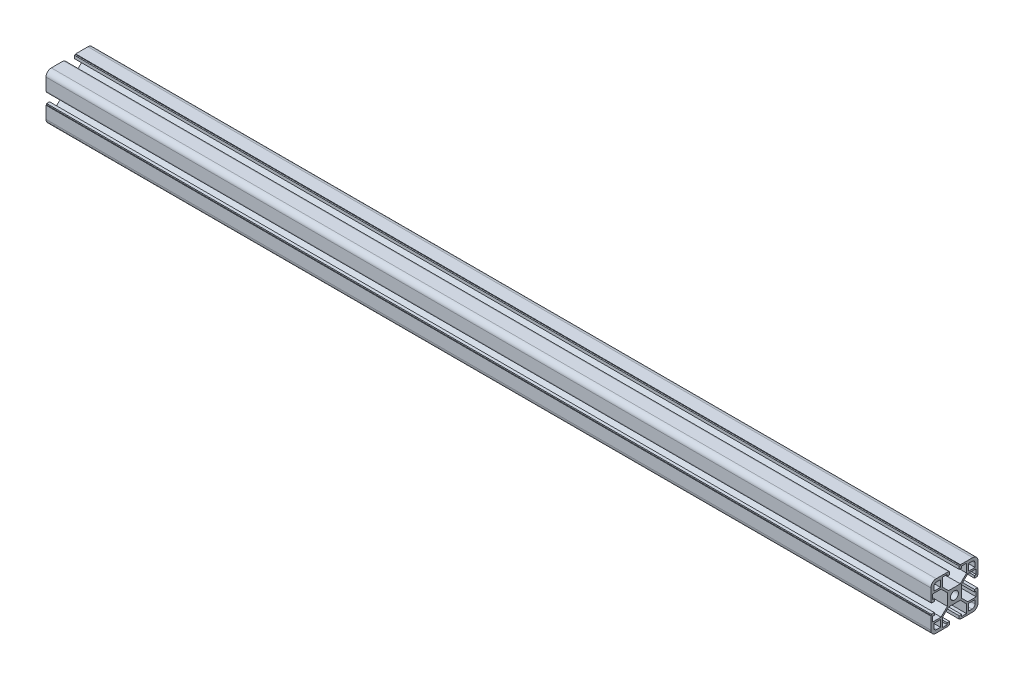
from build123d import *

# Parameters (mm, degrees)
SKETCH1_R                 = 3.4
F_40_X_40L_X_R4_5_1_DEPTH = 750


with BuildPart() as part:
    # Sketch1 → 铝型材 40 X 40L X R4.5(1) (new body)
    with BuildSketch(Plane(origin=(-244.796828543, 0, 0), x_dir=(0, 0, -1), z_dir=(1, 0, 0))):
        with BuildLine():
            Line((-5.1, 20), (-5.1, 19.5))
            Line((-5.1, 19.5), (-4.1, 19.5))
            Line((-4.1, 19.5), (-4.1, 17))
            Line((-4.1, 17), (-6.1, 17))
            Line((-6.1, 17), (-6.1, 18.5))
            Line((-6.1, 18.5), (-10.3, 18.5))
            Line((-10.3, 18.5), (-10.3, 11.3))
            Line((-10.3, 11.3), (-5, 6))
            Line((-5, 6), (5, 6))
            Line((5, 6), (10.3, 11.3))
            Line((10.3, 11.3), (10.3, 18.5))
            Line((10.3, 18.5), (6.1, 18.5))
            Line((6.1, 18.5), (6.1, 17))
            Line((6.1, 17), (4.1, 17))
            Line((4.1, 17), (4.1, 19.5))
            Line((4.1, 19.5), (5.1, 19.5))
            Line((5.1, 19.5), (5.1, 20))
            Line((5.1, 20), (15.5, 20))
            ThreePointArc((15.5, 20), (18.681980515, 18.681980515), (20, 15.5))
            Line((20, 15.5), (20, 5.1))
            Line((20, 5.1), (19.5, 5.1))
            Line((19.5, 5.1), (19.5, 4.1))
            Line((19.5, 4.1), (17, 4.1))
            Line((17, 4.1), (17, 6.1))
            Line((17, 6.1), (18.5, 6.1))
            Line((18.5, 6.1), (18.5, 10.3))
            Line((18.5, 10.3), (11.3, 10.3))
            Line((11.3, 10.3), (6, 5))
            Line((6, 5), (6, -5))
            Line((6, -5), (11.3, -10.3))
            Line((11.3, -10.3), (18.5, -10.3))
            Line((18.5, -10.3), (18.5, -6.1))
            Line((18.5, -6.1), (17, -6.1))
            Line((17, -6.1), (17, -4.1))
            Line((17, -4.1), (19.5, -4.1))
            Line((19.5, -4.1), (19.5, -5.1))
            Line((19.5, -5.1), (20, -5.1))
            Line((20, -5.1), (20, -15.5))
            ThreePointArc((20, -15.5), (18.681980515, -18.681980515), (15.5, -20))
            Line((15.5, -20), (5.1, -20))
            Line((5.1, -20), (5.1, -19.5))
            Line((5.1, -19.5), (4.1, -19.5))
            Line((4.1, -19.5), (4.1, -17))
            Line((4.1, -17), (6.1, -17))
            Line((6.1, -17), (6.1, -18.5))
            Line((6.1, -18.5), (10.3, -18.5))
            Line((10.3, -18.5), (10.3, -11.3))
            Line((10.3, -11.3), (5, -6))
            Line((5, -6), (-5, -6))
            Line((-5, -6), (-10.3, -11.3))
            Line((-10.3, -11.3), (-10.3, -18.5))
            Line((-10.3, -18.5), (-6.1, -18.5))
            Line((-6.1, -18.5), (-6.1, -17))
            Line((-6.1, -17), (-4.1, -17))
            Line((-4.1, -17), (-4.1, -19.5))
            Line((-4.1, -19.5), (-5.1, -19.5))
            Line((-5.1, -19.5), (-5.1, -20))
            Line((-5.1, -20), (-15.5, -20))
            ThreePointArc((-15.5, -20), (-18.681980515, -18.681980515), (-20, -15.5))
            Line((-20, -15.5), (-20, -5.1))
            Line((-20, -5.1), (-19.5, -5.1))
            Line((-19.5, -5.1), (-19.5, -4.1))
            Line((-19.5, -4.1), (-17, -4.1))
            Line((-17, -4.1), (-17, -6.1))
            Line((-17, -6.1), (-18.5, -6.1))
            Line((-18.5, -6.1), (-18.5, -10.3))
            Line((-18.5, -10.3), (-11.3, -10.3))
            Line((-11.3, -10.3), (-6, -5))
            Line((-6, -5), (-6, 5))
            Line((-6, 5), (-11.3, 10.3))
            Line((-11.3, 10.3), (-18.5, 10.3))
            Line((-18.5, 10.3), (-18.5, 6.1))
            Line((-18.5, 6.1), (-17, 6.1))
            Line((-17, 6.1), (-17, 4.1))
            Line((-17, 4.1), (-19.5, 4.1))
            Line((-19.5, 4.1), (-19.5, 5.1))
            Line((-19.5, 5.1), (-20, 5.1))
            Line((-20, 5.1), (-20, 15.5))
            ThreePointArc((-20, 15.5), (-18.681980515, 18.681980515), (-15.5, 20))
            Line((-15.5, 20), (-5.1, 20))
        make_face()
        Circle(SKETCH1_R, mode=Mode.SUBTRACT)
        with BuildLine():
            Line((11.8, 17.5), (15, 17.5))
            ThreePointArc((15, 17.5), (16.767766953, 16.767766953), (17.5, 15))
            Line((17.5, 15), (17.5, 11.8))
            Line((17.5, 11.8), (11.8, 11.8))
            Line((11.8, 11.8), (11.8, 17.5))
        make_face(mode=Mode.SUBTRACT)
        with BuildLine():
            Line((-15, 17.5), (-11.8, 17.5))
            Line((-11.8, 17.5), (-11.8, 11.8))
            Line((-11.8, 11.8), (-17.5, 11.8))
            Line((-17.5, 11.8), (-17.5, 15))
            ThreePointArc((-17.5, 15), (-16.767766953, 16.767766953), (-15, 17.5))
        make_face(mode=Mode.SUBTRACT)
        with BuildLine():
            Line((-17.5, -11.8), (-11.8, -11.8))
            Line((-11.8, -11.8), (-11.8, -17.5))
            Line((-11.8, -17.5), (-15, -17.5))
            ThreePointArc((-15, -17.5), (-16.767766953, -16.767766953), (-17.5, -15))
            Line((-17.5, -15), (-17.5, -11.8))
        make_face(mode=Mode.SUBTRACT)
        with BuildLine():
            Line((11.8, -11.8), (17.5, -11.8))
            Line((17.5, -11.8), (17.5, -15))
            ThreePointArc((17.5, -15), (16.767766953, -16.767766953), (15, -17.5))
            Line((15, -17.5), (11.8, -17.5))
            Line((11.8, -17.5), (11.8, -11.8))
        make_face(mode=Mode.SUBTRACT)
    extrude(amount=F_40_X_40L_X_R4_5_1_DEPTH)


solid = part.part
